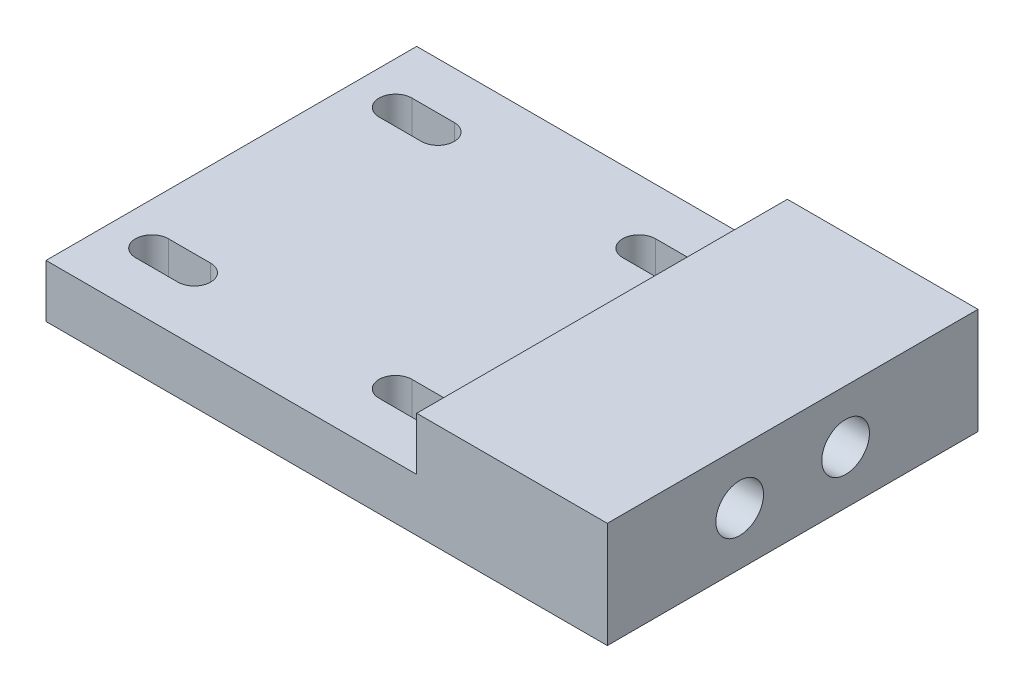
from build123d import *

# Parameters (mm, degrees)
BOSS_EXTRUDE1_DEPTH = 35
SKETCH2_R           = 2.25
CUT_EXTRUDE1_DEPTH  = 10
CUT_EXTRUDE2_DEPTH  = 5


with BuildPart() as part:
    # Sketch1 → Boss-Extrude1 (new body)
    with BuildSketch(Plane.XY):
        Polygon((8.5, 5), (8.5, 0), (-26.5, 0), (-26.5, -5), (26.5, -5), (26.5, 5), align=None)
    extrude(amount=BOSS_EXTRUDE1_DEPTH)

    # Sketch2 → Cut-Extrude1 (cut)
    with BuildSketch(Plane(origin=(26.5, 0, 0), x_dir=(0, 0, -1), z_dir=(1, 0, 0))):
        with Locations((-22.5, 0)):
            Circle(SKETCH2_R)
        with Locations((-12.5, 0)):
            Circle(SKETCH2_R)
    extrude(amount=-CUT_EXTRUDE1_DEPTH, mode=Mode.SUBTRACT)

    # Sketch3 → Cut-Extrude2 (cut)
    with BuildSketch(Plane(origin=(0, 0, 0), x_dir=(1, 0, 0), z_dir=(0, 1, 0))):
        with BuildLine():
            Line((-22.5, -7.55), (-18.5, -7.55))
            ThreePointArc((-18.5, -7.55), (-16.95, -6), (-18.5, -4.45))
            Line((-18.5, -4.45), (-22.5, -4.45))
            ThreePointArc((-22.5, -4.45), (-24.05, -6), (-22.5, -7.55))
        make_face()
        with BuildLine():
            Line((-22.5, -30.55), (-18.5, -30.55))
            ThreePointArc((-18.5, -30.55), (-16.95, -29), (-18.5, -27.45))
            Line((-18.5, -27.45), (-22.5, -27.45))
            ThreePointArc((-22.5, -27.45), (-24.05, -29), (-22.5, -30.55))
        make_face()
        with BuildLine():
            Line((4.5, -4.45), (0.5, -4.45))
            ThreePointArc((0.5, -4.45), (-1.05, -6), (0.5, -7.55))
            Line((0.5, -7.55), (4.5, -7.55))
            ThreePointArc((4.5, -7.55), (6.05, -6), (4.5, -4.45))
        make_face()
        with BuildLine():
            Line((4.5, -27.45), (0.5, -27.45))
            ThreePointArc((0.5, -27.45), (-1.05, -29), (0.5, -30.55))
            Line((0.5, -30.55), (4.5, -30.55))
            ThreePointArc((4.5, -30.55), (6.05, -29), (4.5, -27.45))
        make_face()
    extrude(amount=-CUT_EXTRUDE2_DEPTH, mode=Mode.SUBTRACT)


solid = part.part
